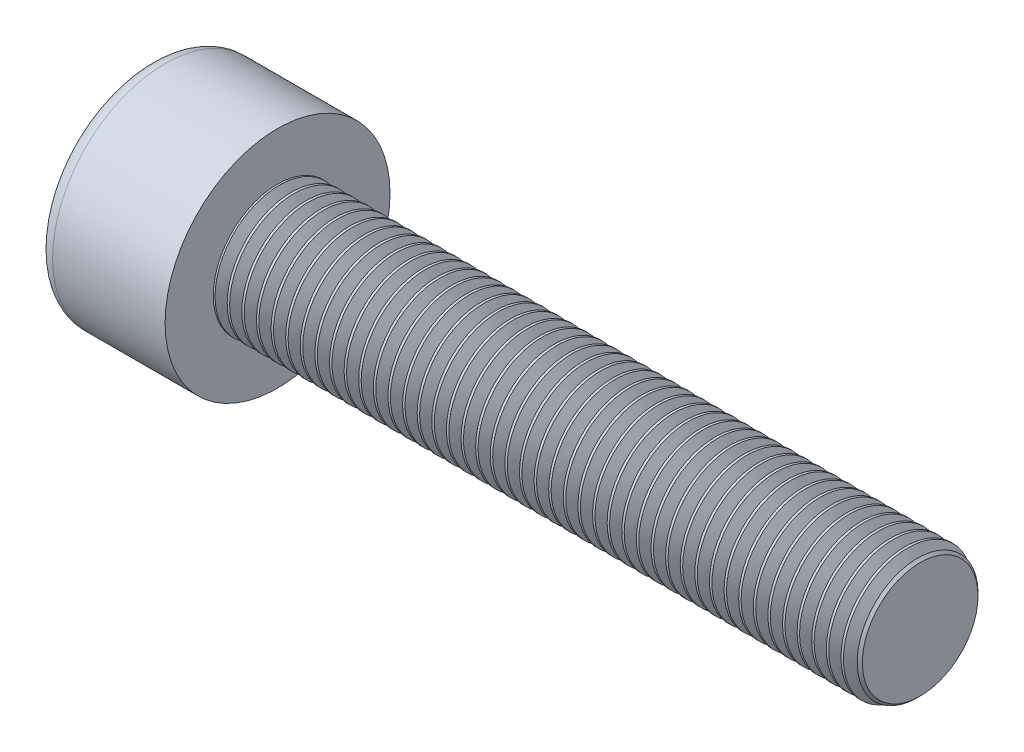
from build123d import *

# Parameters (mm, degrees)
SKETCH1_R           = 3.5
BASEHEAD_DEPTH      = 4
SKETCH2_R           = 2
BASEBODY_DEPTH      = 20
HEXAGONSOCKET_DEPTH = 2
TOPFILLET_R         = 0.5
CHAMFER1_SIZE       = 0.2
LPATTERN10_COUNT    = 44
LPATTERN10_PITCH    = 0.4548


with BuildPart() as part:
    # Sketch1 → BaseHead (new body)
    with BuildSketch(Plane(origin=(0, 0, 0), x_dir=(0, 0, -1), z_dir=(1, 0, 0))):
        Circle(SKETCH1_R)
    extrude(amount=BASEHEAD_DEPTH)

    # Sketch2 → BaseBody (add)
    with BuildSketch(Plane(origin=(4, 0, 0), x_dir=(0, 0, -1), z_dir=(1, 0, 0))):
        Circle(SKETCH2_R)
    extrude(amount=BASEBODY_DEPTH)

    # Sketch3 → HexagonSocket (cut)
    with BuildSketch(Plane(origin=(0, 0, 0), x_dir=(0, 0, -1), z_dir=(1, 0, 0))):
        Polygon((1.732050808, 0), (0.866025404, 1.5), (-0.866025404, 1.5), (-1.732050808, 0), (-0.866025404, -1.5), (0.866025404, -1.5), align=None)
    extrude(amount=HEXAGONSOCKET_DEPTH, mode=Mode.SUBTRACT)

    # Sketch4 → Cut-Revolve1 (revolve, cut)
    with BuildSketch(Plane(origin=(-4.19613823, 0.75, 0), x_dir=(-1, 0, 0), z_dir=(0, 0, 1))):
        Polygon((-6.19613823, 2.25), (-7.062163633, 0.75), (-6.19613823, 0.75), align=None)
    revolve(axis=Axis((0.838992387, 0, 0), (-1, 0, 0)), mode=Mode.SUBTRACT)

    # TopFillet
    topfillet_edges = [part.edges().sort_by_distance(p)[0] for p in [
        (0, 0, 3.5),
    ]]
    fillet(topfillet_edges, radius=TOPFILLET_R)

    # Chamfer1
    chamfer1_edges = [part.edges().sort_by_distance(p)[0] for p in [
        (24, 0, 2),
    ]]
    chamfer(chamfer1_edges, length=CHAMFER1_SIZE)

    # Sketch5 → Cut-Revolve10 (revolve, cut)
    with BuildSketch(Plane.XY):
        Polygon((23.8, 1.671776372), (23.9895, 2), (23.9895, 2.379), (23.6105, 2.379), (23.6105, 2), align=None)
    cut_revolve10 = revolve(axis=Axis((0, 0, 0), (1, 0, 0)), mode=Mode.SUBTRACT)

    # LPattern10: Cut-Revolve10 ×44
    with Locations(*[(-i * LPATTERN10_PITCH, 0, 0) for i in range(1, LPATTERN10_COUNT)]):
        add(cut_revolve10, mode=Mode.SUBTRACT)


solid = part.part
